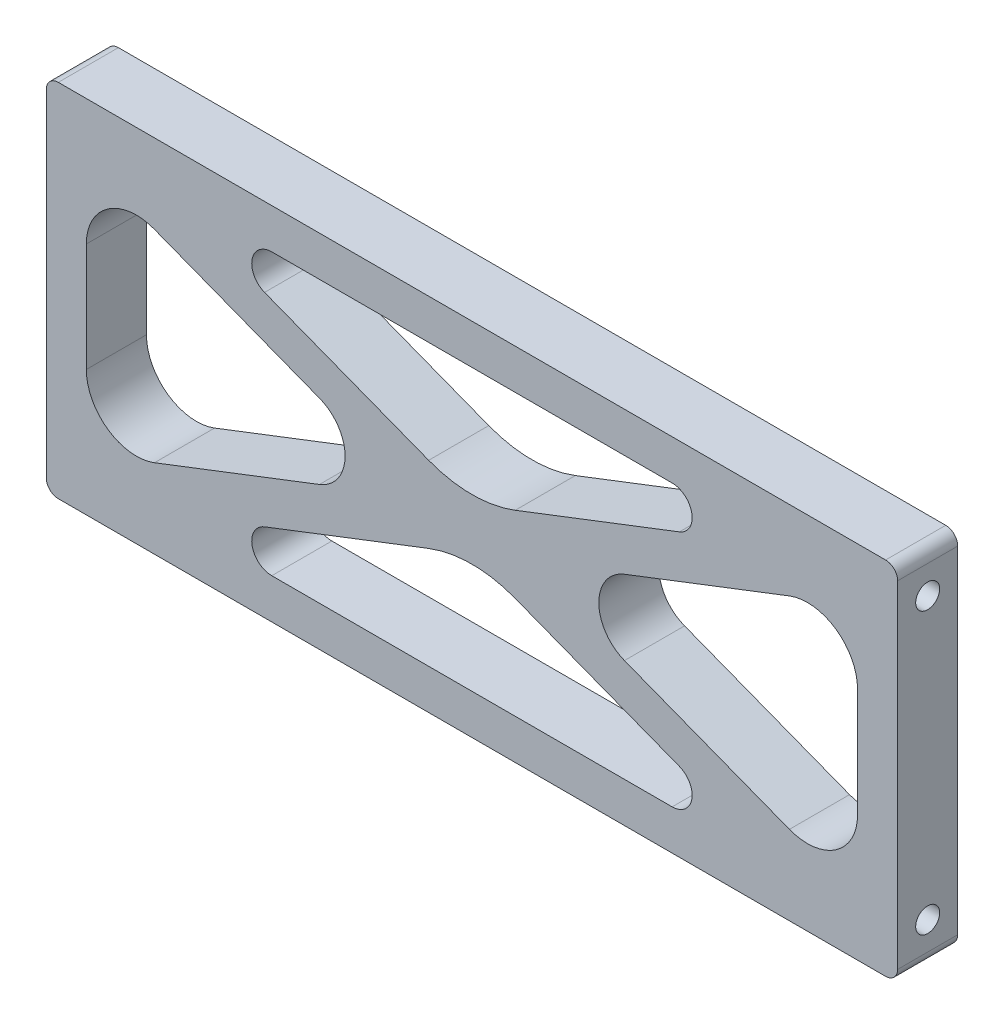
from build123d import *

# Parameters (mm, degrees)
SKETCH1_W                       = 134.9248
SKETCH1_H                       = 57.15
BOSS_EXTRUDE1_DEPTH             = 4.7625
CUT_EXTRUDE1_DEPTH              = 10.525
F_10_24_TAPPED_HOLE1_AT_2_COUNT = 2
F_10_24_TAPPED_HOLE1_AT_2_PITCH = 44.45
FILLET1_R                       = 1.905


with BuildPart() as part:
    # Sketch1 → Boss-Extrude1 (new body, symmetric)
    with BuildSketch(Plane.XY):
        Rectangle(SKETCH1_W, SKETCH1_H)
    extrude(amount=BOSS_EXTRUDE1_DEPTH, both=True)

    # Sketch3 → Cut-Extrude1 (cut, through all)
    with BuildSketch(Plane.XY.offset(4.7625)):
        with BuildLine():
            Line((-61.1124, 8.609886798), (-61.1124, -8.609886798))
            ThreePointArc((-61.1124, -8.609886798), (-57.664894583, -15.155408542), (-50.317097979, -16.015079156))
            Line((-50.317097979, -16.015079156), (-24.169295524, -5.924153886))
            ThreePointArc((-24.169295524, -5.924153886), (-20.105537141, 0), (-24.169295524, 5.924153886))
            Line((-24.169295524, 5.924153886), (-50.317097979, 16.015079156))
            ThreePointArc((-50.317097979, 16.015079156), (-57.664894583, 15.155408542), (-61.1124, 8.609886798))
        make_face()
        with BuildLine():
            Line((-31.725706947, -22.225), (31.725706947, -22.225))
            ThreePointArc((31.725706947, -22.225), (34.847022318, -19.631390878), (32.868827755, -16.087923057))
            Line((32.868827755, -16.087923057), (6.85872485, -6.050138615))
            ThreePointArc((6.85872485, -6.050138615), (0, -4.772600274), (-6.85872485, -6.050138615))
            Line((-6.85872485, -6.050138615), (-32.868827755, -16.087923057))
            ThreePointArc((-32.868827755, -16.087923057), (-34.847022318, -19.631390878), (-31.725706947, -22.225))
        make_face()
        with BuildLine():
            Line((-31.725706947, 22.225), (31.725706947, 22.225))
            ThreePointArc((31.725706947, 22.225), (34.847022318, 19.631390878), (32.868827755, 16.087923057))
            Line((32.868827755, 16.087923057), (6.85872485, 6.050138615))
            ThreePointArc((6.85872485, 6.050138615), (0, 4.772600274), (-6.85872485, 6.050138615))
            Line((-6.85872485, 6.050138615), (-32.868827755, 16.087923057))
            ThreePointArc((-32.868827755, 16.087923057), (-34.847022318, 19.631390878), (-31.725706947, 22.225))
        make_face()
        with BuildLine():
            Line((61.1124, 8.609886798), (61.1124, -8.609886798))
            ThreePointArc((61.1124, -8.609886798), (57.664894583, -15.155408542), (50.317097979, -16.015079156))
            Line((50.317097979, -16.015079156), (24.169295524, -5.924153886))
            ThreePointArc((24.169295524, -5.924153886), (20.105537141, 0), (24.169295524, 5.924153886))
            Line((24.169295524, 5.924153886), (50.317097979, 16.015079156))
            ThreePointArc((50.317097979, 16.015079156), (57.664894583, 15.155408542), (61.1124, 8.609886798))
        make_face()
    extrude(amount=-CUT_EXTRUDE1_DEPTH, mode=Mode.SUBTRACT)

    # Sketch4 → #10-24 Tapped Hole1 (revolve, cut)
    with BuildSketch(Plane(origin=(-67.4624, 22.225, 0), x_dir=(0, 0, 1), z_dir=(0, 1, 0))):
        Polygon((0, 0), (0, 14.094824014), (1.89865, 12.954), (1.89865, 0), align=None)
    f_10_24_tapped_hole1 = revolve(axis=Axis((-73.8124, 22.225, 0), (1, 0, 0)), mode=Mode.SUBTRACT)

    # #10-24 Tapped Hole1 at 2: #10-24 Tapped Hole1 ×2
    with Locations(*[(0, -i * F_10_24_TAPPED_HOLE1_AT_2_PITCH, 0) for i in range(1, F_10_24_TAPPED_HOLE1_AT_2_COUNT)]):
        add(f_10_24_tapped_hole1, mode=Mode.SUBTRACT)

    # Mirror1: #10-24 Tapped Hole1 across plane
    add(f_10_24_tapped_hole1.mirror(Plane(origin=(0, 0, 0), x_dir=(0, 0, 1), z_dir=(1, 0, 0))), mode=Mode.SUBTRACT)

    # Mirror1 copy 1 sketch → Mirror1 copy 1 (revolve, cut)
    with BuildSketch(Plane(origin=(67.4624, -22.225, 0), x_dir=(0, 0, 1), z_dir=(0, 1, 0))):
        Polygon((0, 0), (0, -14.094824014), (1.89865, -12.954), (1.89865, 0), align=None)
    revolve(axis=Axis((73.8124, -22.225, 0), (1, 0, 0)), mode=Mode.SUBTRACT)

    # Fillet1
    fillet1_edges = [part.edges().sort_by_distance(p)[0] for p in [
        (67.4624, -28.575, 0),
        (-67.4624, -28.575, 0),
        (-67.4624, 28.575, 0),
        (67.4624, 28.575, 0),
    ]]
    fillet(fillet1_edges, radius=FILLET1_R)


solid = part.part
